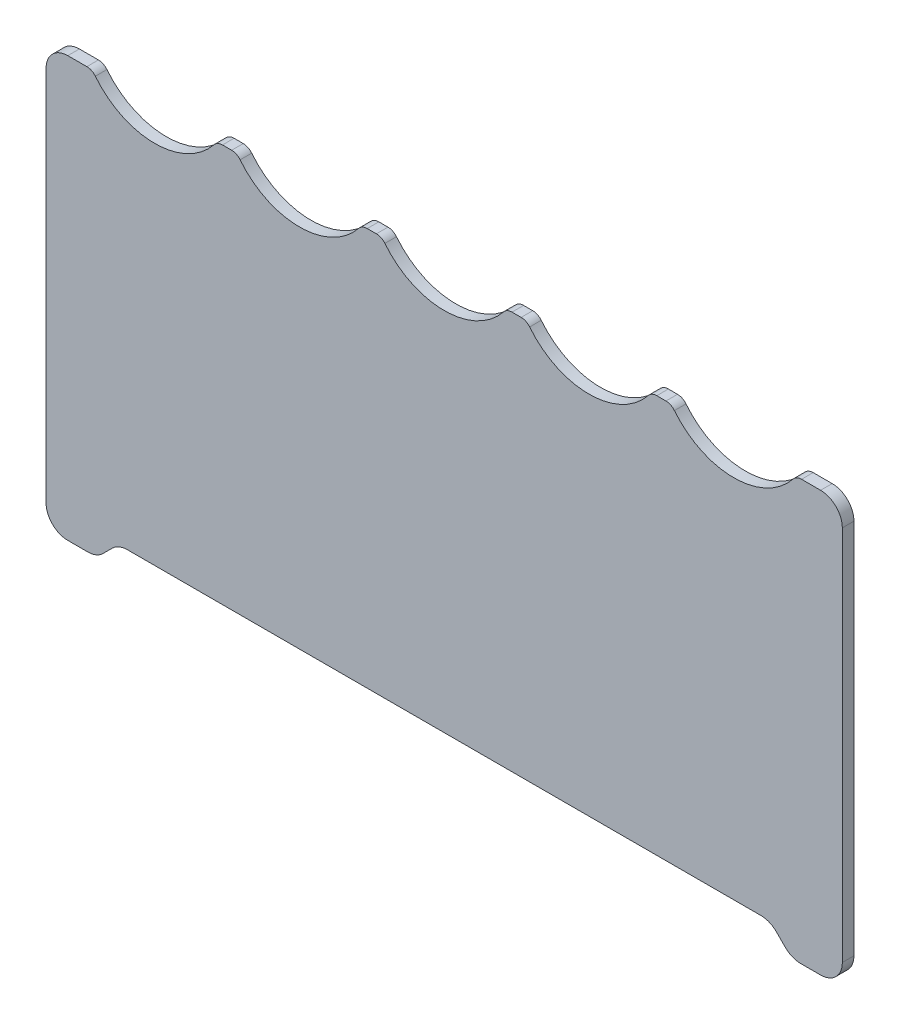
from build123d import *

# Parameters (mm, degrees)
BOSS_EXTRUDE1_DEPTH = 1.6


with BuildPart() as part:
    # Sketch2 → Boss-Extrude1 (new body)
    with BuildSketch(Plane.XY):
        with BuildLine():
            Line((-47.121320344, 0.878679656), (-45.878679656, 2.121320344))
            ThreePointArc((-45.878679656, 2.121320344), (-44.90540961, 2.771638598), (-43.757359313, 3))
            Line((-43.757359313, 3), (43.757359313, 3))
            ThreePointArc((43.757359313, 3), (44.90540961, 2.771638598), (45.878679656, 2.121320344))
            Line((45.878679656, 2.121320344), (47.121320344, 0.878679656))
            ThreePointArc((47.121320344, 0.878679656), (48.09459039, 0.228361402), (49.242640687, 0))
            Line((49.242640687, 0), (52, 0))
            ThreePointArc((52, 0), (54.121320344, 0.878679656), (55, 3))
            Line((55, 3), (55, 55))
            ThreePointArc((55, 55), (54.121320344, 57.121320344), (52, 58))
            Line((52, 58), (49.367496998, 58))
            ThreePointArc((49.367496998, 58), (48.717977945, 57.852081728), (48.196559873, 57.4375))
            ThreePointArc((48.196559873, 57.4375), (40, 53.5), (31.803440127, 57.4375))
            ThreePointArc((31.803440127, 57.4375), (31.282022055, 57.852081728), (30.632503002, 58))
            Line((30.632503002, 58), (29.367496998, 58))
            ThreePointArc((29.367496998, 58), (28.717977945, 57.852081728), (28.196559873, 57.4375))
            ThreePointArc((28.196559873, 57.4375), (20, 53.5), (11.803440127, 57.4375))
            ThreePointArc((11.803440127, 57.4375), (11.282022055, 57.852081728), (10.632503002, 58))
            Line((10.632503002, 58), (9.367496998, 58))
            ThreePointArc((9.367496998, 58), (8.717977945, 57.852081728), (8.196559873, 57.4375))
            ThreePointArc((8.196559873, 57.4375), (0, 53.5), (-8.196559873, 57.4375))
            ThreePointArc((-8.196559873, 57.4375), (-8.717977945, 57.852081728), (-9.367496998, 58))
            Line((-9.367496998, 58), (-10.632503002, 58))
            ThreePointArc((-10.632503002, 58), (-11.282022055, 57.852081728), (-11.803440127, 57.4375))
            ThreePointArc((-11.803440127, 57.4375), (-20, 53.5), (-28.196559873, 57.4375))
            ThreePointArc((-28.196559873, 57.4375), (-28.717977945, 57.852081728), (-29.367496998, 58))
            Line((-29.367496998, 58), (-30.632503002, 58))
            ThreePointArc((-30.632503002, 58), (-31.282022055, 57.852081728), (-31.803440127, 57.4375))
            ThreePointArc((-31.803440127, 57.4375), (-40, 53.5), (-48.196559873, 57.4375))
            ThreePointArc((-48.196559873, 57.4375), (-48.717977945, 57.852081728), (-49.367496998, 58))
            Line((-49.367496998, 58), (-52, 58))
            ThreePointArc((-52, 58), (-54.121320344, 57.121320344), (-55, 55))
            Line((-55, 55), (-55, 3))
            ThreePointArc((-55, 3), (-54.121320344, 0.878679656), (-52, 0))
            Line((-52, 0), (-49.242640687, 0))
            ThreePointArc((-49.242640687, 0), (-48.09459039, 0.228361402), (-47.121320344, 0.878679656))
        make_face()
    extrude(amount=BOSS_EXTRUDE1_DEPTH)


solid = part.part
